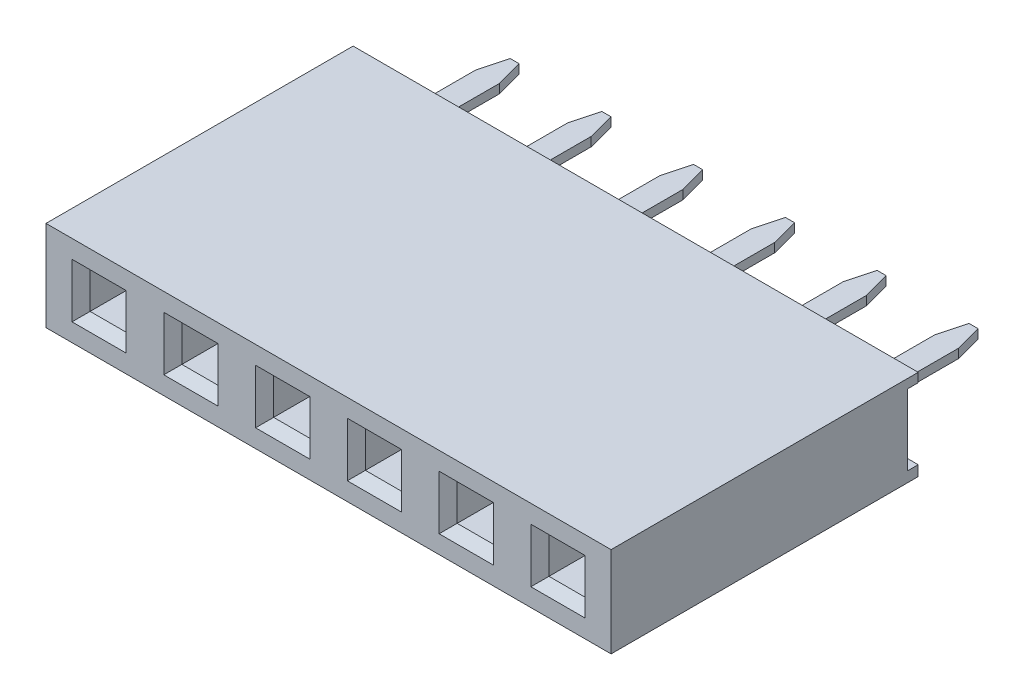
from build123d import *

# Parameters (mm, degrees)
SKETCH1_W                  = 15.64
SKETCH1_H                  = 2.5
BOSS_EXTRUDE1_DEPTH        = 8.5
SKETCH2_W                  = 1
SKETCH2_H                  = 1
CUT_EXTRUDE1_DEPTH         = 2.25
CHAMFER1_SIZE              = 0.25
SKETCH3_W                  = 0.3
SKETCH3_H                  = 1.963850618
CUT_EXTRUDE2_DEPTH         = 16.64
SKETCH4_W                  = 0.65
SKETCH4_H                  = 3.3
BOSS_EXTRUDE2_DEPTH        = 0.125
CHAMFER2_SIZE              = 0.2
CHAMFER2_SIZE2             = 0.746410162
LPATTERN4_COUNT            = 6
LPATTERN4_PITCH            = 2.54
LPATTERN5_COUNT            = 6
LPATTERN5_PITCH            = 2.54
CHAMFER1_OF_LPATTERN5_SIZE = 0.25


with BuildPart() as part:
    # Sketch1 → Boss-Extrude1 (new body)
    with BuildSketch(Plane.XY):
        with Locations((7.82, 1.25)):
            Rectangle(SKETCH1_W, SKETCH1_H)
    extrude(amount=BOSS_EXTRUDE1_DEPTH)

    # Sketch2 → Cut-Extrude1 (cut)
    with BuildSketch(Plane.XY.offset(8.5)):
        with Locations((1.47, 1.25)):
            Rectangle(SKETCH2_W, SKETCH2_H)
    cut_extrude1 = extrude(amount=-CUT_EXTRUDE1_DEPTH, mode=Mode.SUBTRACT)

    # Chamfer1
    chamfer1_edges = [part.edges().sort_by_distance(p)[0] for p in [
        (0.97, 1.25, 8.5),
        (1.47, 0.75, 8.5),
        (1.97, 1.25, 8.5),
        (1.47, 1.75, 8.5),
    ]]
    chamfer(chamfer1_edges, length=CHAMFER1_SIZE)

    # Sketch3 → Cut-Extrude2 (cut, through all)
    with BuildSketch(Plane.ZY):
        with Locations((0.15, 1.268074691)):
            Rectangle(SKETCH3_W, SKETCH3_H)
    extrude(amount=-CUT_EXTRUDE2_DEPTH, mode=Mode.SUBTRACT)

    # LPattern5: Cut-Extrude1 ×6
    with Locations(*[(i * LPATTERN5_PITCH, 0, 0) for i in range(1, LPATTERN5_COUNT)]):
        add(cut_extrude1, mode=Mode.SUBTRACT)

    # Chamfer1 of LPattern5
    chamfer1_of_lpattern5_edges = [part.edges().sort_by_distance(p)[0] for p in [
        (3.51, 1.25, 8.5),
        (4.01, 0.75, 8.5),
        (4.51, 1.25, 8.5),
        (4.01, 1.75, 8.5),
        (6.05, 1.25, 8.5),
        (6.55, 0.75, 8.5),
        (7.05, 1.25, 8.5),
        (6.55, 1.75, 8.5),
        (8.59, 1.25, 8.5),
        (9.09, 0.75, 8.5),
        (9.59, 1.25, 8.5),
        (9.09, 1.75, 8.5),
        (11.13, 1.25, 8.5),
        (11.63, 0.75, 8.5),
        (12.13, 1.25, 8.5),
        (11.63, 1.75, 8.5),
        (13.67, 1.25, 8.5),
        (14.17, 0.75, 8.5),
        (14.67, 1.25, 8.5),
        (14.17, 1.75, 8.5),
    ]]
    chamfer(chamfer1_of_lpattern5_edges, length=CHAMFER1_OF_LPATTERN5_SIZE)


with BuildPart() as body_2:
    # Sketch4 → Boss-Extrude2 (new body, symmetric)
    with BuildSketch(Plane(origin=(0, 1.25, 0), x_dir=(-1, 0, 0), z_dir=(0, -1, 0))):
        with Locations((-1.47, 1.35)):
            Rectangle(SKETCH4_W, SKETCH4_H)
    extrude(amount=BOSS_EXTRUDE2_DEPTH, both=True)

    # Chamfer2
    chamfer2_edges = [body_2.edges().sort_by_distance(p)[0] for p in [
        (1.795, 1.25, -3),
        (1.145, 1.25, -3),
    ]]
    chamfer2_side = [body_2.faces().sort_by_distance(p)[0] for p in [
        (1.47, 1.25, -3),
    ]]
    chamfer(chamfer2_edges, length=CHAMFER2_SIZE, length2=CHAMFER2_SIZE2, reference=chamfer2_side[0])


with BuildPart() as lpattern4_1:
    # LPattern4: pattern copy
    add(body_2.part.moved(Location(Vector(1, 0, 0) * (1 * LPATTERN4_PITCH))))


with BuildPart() as lpattern4_2:
    # LPattern4: pattern copy
    add(body_2.part.moved(Location(Vector(1, 0, 0) * (2 * LPATTERN4_PITCH))))


with BuildPart() as lpattern4_3:
    # LPattern4: pattern copy
    add(body_2.part.moved(Location(Vector(1, 0, 0) * (3 * LPATTERN4_PITCH))))


with BuildPart() as lpattern4_4:
    # LPattern4: pattern copy
    add(body_2.part.moved(Location(Vector(1, 0, 0) * (4 * LPATTERN4_PITCH))))


with BuildPart() as lpattern4_5:
    # LPattern4: pattern copy
    add(body_2.part.moved(Location(Vector(1, 0, 0) * (5 * LPATTERN4_PITCH))))


solid = Compound([part.part, body_2.part, lpattern4_1.part, lpattern4_2.part, lpattern4_3.part, lpattern4_4.part, lpattern4_5.part])
